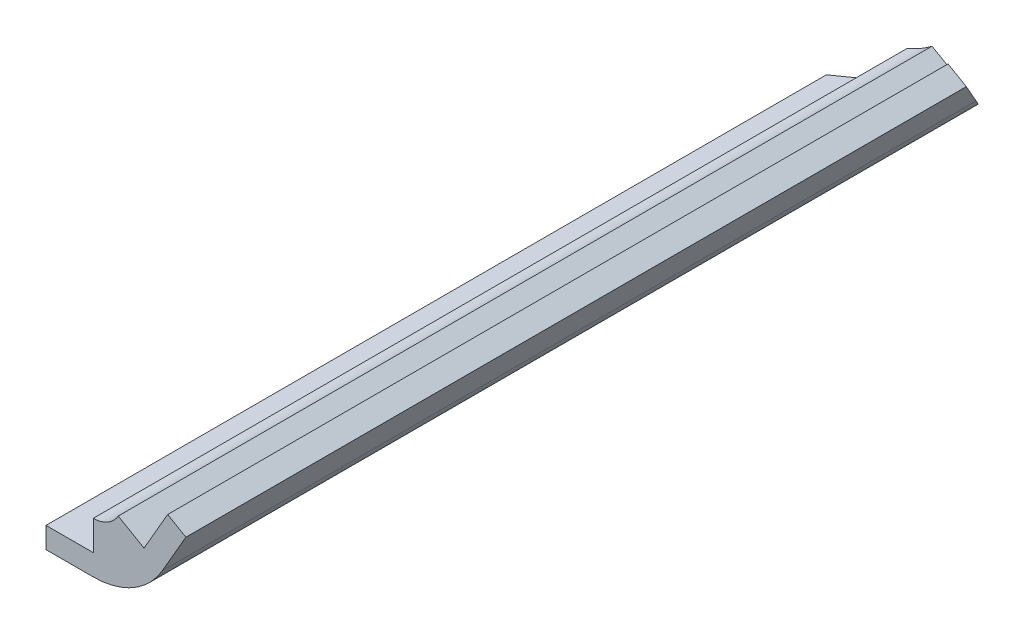
from build123d import *

# Parameters (mm, degrees)
SKETCH7_W               = 4.7625
SKETCH7_H               = 2.12122512
BOSS_EXTRUDE2_DEPTH     = 130.175
BOSS_EXTRUDE3_DEPTH     = 130.175
BOSS_EXTRUDE4_DEPTH     = 130.175
CUT_EXTRUDE1_DEPTH      = 177.833619085
CUT_EXTRUDE1_DEPTH_BACK = 177.833619085


with BuildPart() as part:
    # Sketch7 → Boss-Extrude2 (new, symmetric)
    with BuildSketch(Plane.XY):
        with Locations((-4.92125, -2.560612608)):
            Rectangle(SKETCH7_W, SKETCH7_H)
    extrude(amount=BOSS_EXTRUDE2_DEPTH, both=True)



with BuildPart() as body_2:
    # Sketch8 → Boss-Extrude3 (new, symmetric)
    with BuildSketch(Plane.XY):
        Polygon((2.569038147, 1.449704502), (4.950288147, 5.574150487), (6.787322988, 4.513537927), (4.406072988, 0.389091942), align=None)
    extrude(amount=BOSS_EXTRUDE3_DEPTH, both=True)


with BuildPart() as part_1:
    add(part.part)

    add(body_2.part)  # Boss-Extrude4 merges body 2
    # Sketch11 → Boss-Extrude4 (add, symmetric)
    with BuildSketch(Plane.XY):
        with BuildLine():
            Line((-2.54, -1.500000048), (-7.3025, -1.500000048))
            Line((-7.3025, -1.500000048), (-7.3025, -3.621225168))
            Line((-7.3025, -3.621225168), (-2.54, -3.621225168))
            ThreePointArc((-2.54, -3.621225168), (1.47031711, -2.546663937), (4.406072988, 0.389091942))
            Line((4.406072988, 0.389091942), (6.787322988, 4.513537927))
            Line((6.787322988, 4.513537927), (4.950288147, 5.574150487))
            Line((4.950288147, 5.574150487), (2.569038147, 1.449704502))
            Line((2.569038147, 1.449704502), (-0.029038147, 2.94970455))
            ThreePointArc((-0.029038147, 2.94970455), (-1.090295498, 1.888447198), (-2.54, 1.500000048))
            Line((-2.54, 1.500000048), (-2.54, -1.500000048))
        make_face()
    extrude(amount=BOSS_EXTRUDE4_DEPTH, both=True)

    # Sketch17 → Cut-Extrude1 (cut, two sides: drawn at the far end of the back side and taken through both)
    with BuildSketch(Plane(origin=(0, 0, 46.419822061), x_dir=(-0.6666666666666663, -0.5773502691896272, 0.4714045207910306), z_dir=(0.47140452079103357, -0.8164965809277251, -0.33333333333333304)).offset(-CUT_EXTRUDE1_DEPTH_BACK)):
        Polygon((304.8, 0), (0, 0), (-152.4, -263.964543073), (-304.8, 0), (-152.4, 263.964543073), (152.4, 263.964543073), align=None)
    extrude(amount=CUT_EXTRUDE1_DEPTH + CUT_EXTRUDE1_DEPTH_BACK, mode=Mode.SUBTRACT)


solid = part_1.part
